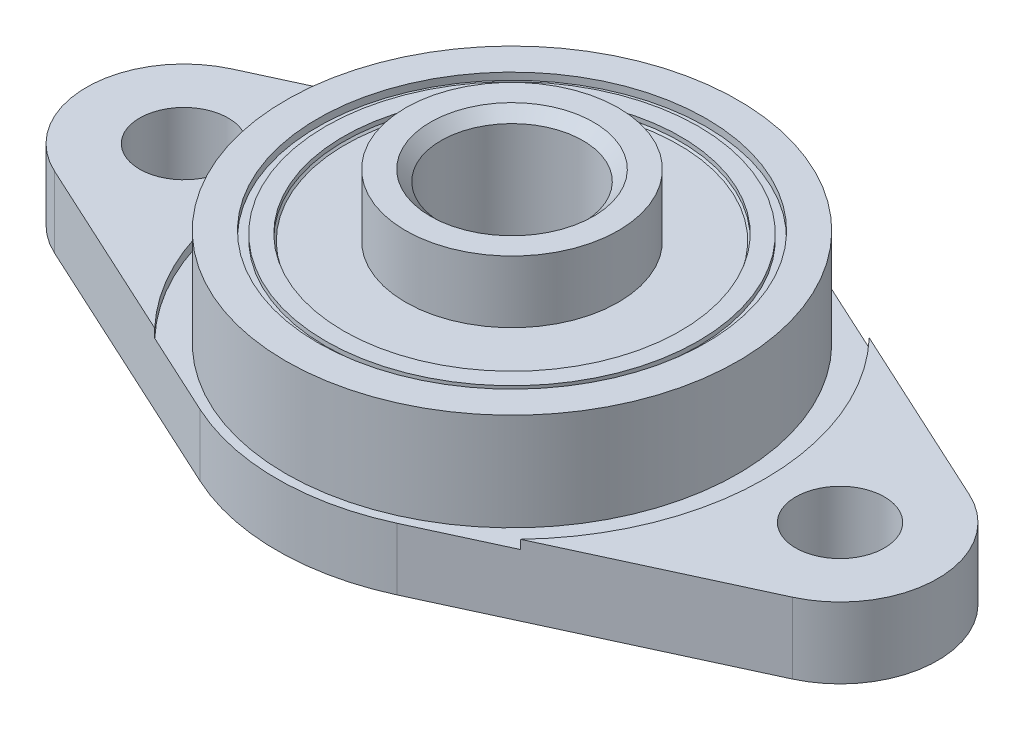
from build123d import *

# Parameters (mm, degrees)
SKETCH2_R               = 2.5
BOSS_EXTRUDE1_DEPTH     = 4
SKETCH3_R               = 14.25
CUT_EXTRUDE1_DEPTH      = 0.5
SKETCH4_R               = 12.75
BOSS_EXTRUDE2_DEPTH     = 5.5
CUT_EXTRUDE2_DEPTH      = 0.5
SKETCH6_R               = 10.95
CUT_EXTRUDE3_DEPTH      = 0.4
SKETCH7_R               = 10.5
BOSS_EXTRUDE3_DEPTH     = 0.25
SKETCH8_R               = 9.5
CUT_EXTRUDE4_DEPTH      = 0.35
SKETCH9_R               = 10.5
BOSS_EXTRUDE4_DEPTH     = 0.25
SKETCH10_R              = 9.5
CUT_EXTRUDE5_DEPTH      = 0.35
SKETCH11_R              = 6
BOSS_EXTRUDE5_DEPTH     = 0.35
SKETCH12_R              = 6
BOSS_EXTRUDE6_DEPTH     = 3.5
SKETCH13_R              = 4
CUT_EXTRUDE6_DEPTH      = 1
CUT_EXTRUDE6_DEPTH_BACK = 13
CHAMFER1_SIZE           = 0.6
CHAMFER2_SIZE           = 0.6
CHAMFER3_SIZE           = 0.1


with BuildPart() as part:
    # Sketch2 → Boss-Extrude1 (new body)
    with BuildSketch(Plane(origin=(0, 0, 0), x_dir=(1, 0, 0), z_dir=(0, 1, 0))):
        with BuildLine():
            Line((-5.550675676, 12.031313293), (-20.804054054, 4.994130046))
            ThreePointArc((-20.804054054, 4.994130046), (-24, 0), (-20.804054054, -4.994130046))
            Line((-20.804054054, -4.994130046), (-5.550675676, -12.031313293))
            ThreePointArc((-5.550675676, -12.031313293), (0, -13.25), (5.550675676, -12.031313293))
            Line((5.550675676, -12.031313293), (20.804054054, -4.994130046))
            ThreePointArc((20.804054054, -4.994130046), (24, 0), (20.804054054, 4.994130046))
            Line((20.804054054, 4.994130046), (5.550675676, 12.031313293))
            ThreePointArc((5.550675676, 12.031313293), (0, 13.25), (-5.550675676, 12.031313293))
        make_face()
        with Locations((-18.5, 0)):
            Circle(SKETCH2_R, mode=Mode.SUBTRACT)
        with Locations((18.5, 0)):
            Circle(SKETCH2_R, mode=Mode.SUBTRACT)
    extrude(amount=BOSS_EXTRUDE1_DEPTH)

    # Sketch3 → Cut-Extrude1 (cut)
    with BuildSketch(Plane(origin=(0, 4, 0), x_dir=(1, 0, 0), z_dir=(0, 1, 0))):
        Circle(SKETCH3_R)
    extrude(amount=-CUT_EXTRUDE1_DEPTH, mode=Mode.SUBTRACT)

    # Sketch4 → Boss-Extrude2 (add)
    with BuildSketch(Plane(origin=(0, 3.5, 0), x_dir=(1, 0, 0), z_dir=(0, 1, 0))):
        Circle(SKETCH4_R)
    extrude(amount=BOSS_EXTRUDE2_DEPTH)

    # Sketch5 → Cut-Extrude2 (cut)
    with BuildSketch(Plane.XZ):
        with BuildLine():
            Line((4.838513514, -10.487673097), (16.48142728, -5.116186488))
            ThreePointArc((16.48142728, -5.116186488), (13, 0), (16.48142728, 5.116186488))
            Line((16.48142728, 5.116186488), (4.838513514, 10.487673097))
            ThreePointArc((4.838513514, 10.487673097), (0, 11.55), (-4.838513514, 10.487673097))
            Line((-4.838513514, 10.487673097), (-16.48142728, 5.116186488))
            ThreePointArc((-16.48142728, 5.116186488), (-13, 0), (-16.48142728, -5.116186488))
            Line((-16.48142728, -5.116186488), (-4.838513514, -10.487673097))
            ThreePointArc((-4.838513514, -10.487673097), (0, -11.55), (4.838513514, -10.487673097))
        make_face()
    extrude(amount=-CUT_EXTRUDE2_DEPTH, mode=Mode.SUBTRACT)

    # Sketch6 → Cut-Extrude3 (cut)
    with BuildSketch(Plane(origin=(0, 9, 0), x_dir=(1, 0, 0), z_dir=(0, 1, 0))):
        Circle(SKETCH6_R)
    extrude(amount=-CUT_EXTRUDE3_DEPTH, mode=Mode.SUBTRACT)

    # Sketch7 → Boss-Extrude3 (add)
    with BuildSketch(Plane(origin=(0, 8.6, 0), x_dir=(1, 0, 0), z_dir=(0, 1, 0))):
        Circle(SKETCH7_R)
    extrude(amount=BOSS_EXTRUDE3_DEPTH)

    # Sketch8 → Cut-Extrude4 (cut)
    with BuildSketch(Plane(origin=(0, 8.85, 0), x_dir=(1, 0, 0), z_dir=(0, 1, 0))):
        Circle(SKETCH8_R)
    extrude(amount=-CUT_EXTRUDE4_DEPTH, mode=Mode.SUBTRACT)

    # Sketch9 → Boss-Extrude4 (add)
    with BuildSketch(Plane.XZ.offset(-0.5)):
        Circle(SKETCH9_R)
    extrude(amount=BOSS_EXTRUDE4_DEPTH)

    # Sketch10 → Cut-Extrude5 (cut)
    with BuildSketch(Plane.XZ.offset(-0.25)):
        Circle(SKETCH10_R)
    extrude(amount=-CUT_EXTRUDE5_DEPTH, mode=Mode.SUBTRACT)

    # Sketch11 → Boss-Extrude5 (add)
    with BuildSketch(Plane.XZ.offset(-0.6)):
        Circle(SKETCH11_R)
    extrude(amount=BOSS_EXTRUDE5_DEPTH)

    # Sketch12 → Boss-Extrude6 (add)
    with BuildSketch(Plane(origin=(0, 8.5, 0), x_dir=(1, 0, 0), z_dir=(0, 1, 0))):
        Circle(SKETCH12_R)
    extrude(amount=BOSS_EXTRUDE6_DEPTH)

    # Sketch13 → Cut-Extrude6 (cut, two sides)
    with BuildSketch(Plane(origin=(0, 12, 0), x_dir=(1, 0, 0), z_dir=(0, 1, 0))) as cut_extrude6_sk:
        Circle(SKETCH13_R)
    extrude(amount=CUT_EXTRUDE6_DEPTH, mode=Mode.SUBTRACT)
    extrude(cut_extrude6_sk.sketch, amount=-CUT_EXTRUDE6_DEPTH_BACK, mode=Mode.SUBTRACT)

    # Chamfer1
    chamfer1_edges = [part.edges().sort_by_distance(p)[0] for p in [
        (-4, 12, 0),
    ]]
    chamfer(chamfer1_edges, length=CHAMFER1_SIZE)

    # Chamfer2
    chamfer2_edges = [part.edges().sort_by_distance(p)[0] for p in [
        (-4, 0.25, 0),
    ]]
    chamfer(chamfer2_edges, length=CHAMFER2_SIZE)

    # Chamfer3
    chamfer3_edges = [part.edges().sort_by_distance(p)[0] for p in [
        (-9.5, 0.6, 0),
        (-9.5, 8.5, 0),
    ]]
    chamfer(chamfer3_edges, length=CHAMFER3_SIZE)


solid = part.part
